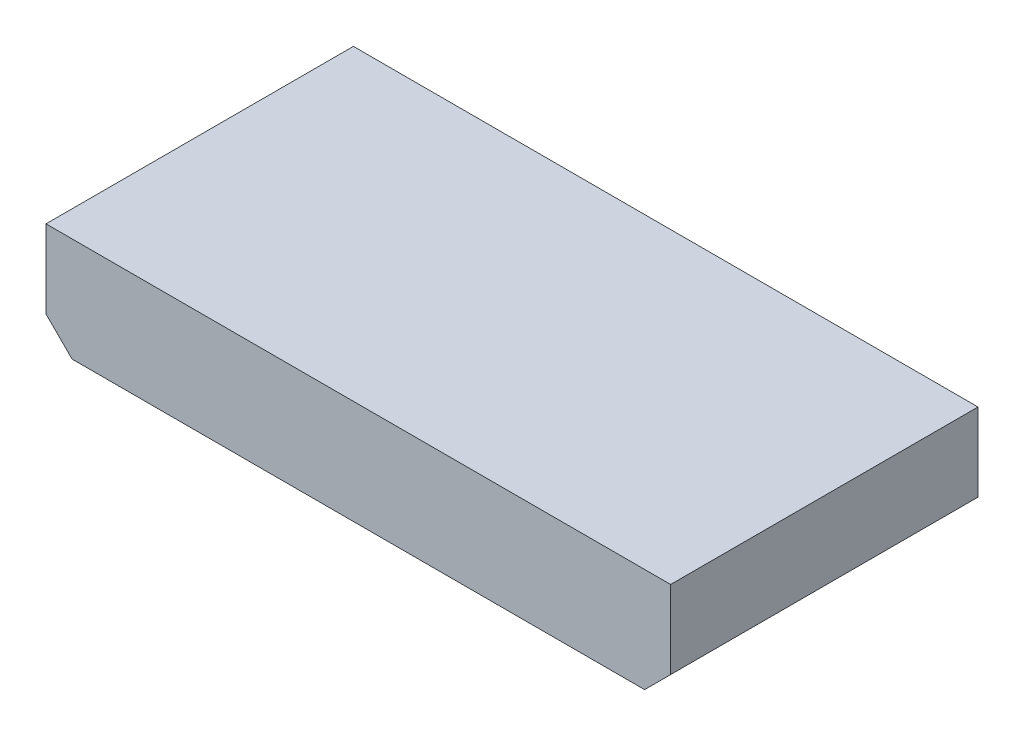
from build123d import *

# Parameters (mm, degrees)
COMPONENT_OUTLINE_DEPTH = 15
SKETCH2_R               = 0.25
EXTRUDE_1_DEPTH         = 2
SKETCH3_R               = 0.25
EXTRUDE_2_DEPTH         = 2
SKETCH4_R               = 0.25
EXTRUDE_3_DEPTH         = 2
SKETCH5_R               = 0.25
EXTRUDE_4_DEPTH         = 2
SKETCH6_R               = 0.25
EXTRUDE_5_DEPTH         = 2
SKETCH7_R               = 0.25
EXTRUDE_6_DEPTH         = 2
SKETCH8_R               = 0.25
EXTRUDE_7_DEPTH         = 2
SKETCH9_R               = 0.25
EXTRUDE_8_DEPTH         = 2
SKETCH10_R              = 0.25
EXTRUDE_9_DEPTH         = 2


with BuildPart() as part:
    # Sketch1 → Component_Outline (new body)
    with BuildSketch(Plane.XY):
        Polygon((-5.08, 2.54), (-5.08, -1.27), (-3.81, -2.54), (24.13, -2.54), (25.4, -1.27), (25.4, 2.54), align=None)
    extrude(amount=COMPONENT_OUTLINE_DEPTH)


with BuildPart() as body_2:
    # Sketch2 → Extrude 1 (new body)
    with BuildSketch(Plane.XY):
        Circle(SKETCH2_R)
    extrude(amount=-EXTRUDE_1_DEPTH)


with BuildPart() as body_3:
    # Sketch3 → Extrude 2 (new body)
    with BuildSketch(Plane.XY):
        with Locations((2.54, 0)):
            Circle(SKETCH3_R)
    extrude(amount=-EXTRUDE_2_DEPTH)


with BuildPart() as body_4:
    # Sketch4 → Extrude 3 (new body)
    with BuildSketch(Plane.XY):
        with Locations((5.08, 0)):
            Circle(SKETCH4_R)
    extrude(amount=-EXTRUDE_3_DEPTH)


with BuildPart() as body_5:
    # Sketch5 → Extrude 4 (new body)
    with BuildSketch(Plane.XY):
        with Locations((7.62, 0)):
            Circle(SKETCH5_R)
    extrude(amount=-EXTRUDE_4_DEPTH)


with BuildPart() as body_6:
    # Sketch6 → Extrude 5 (new body)
    with BuildSketch(Plane.XY):
        with Locations((10.16, 0)):
            Circle(SKETCH6_R)
    extrude(amount=-EXTRUDE_5_DEPTH)


with BuildPart() as body_7:
    # Sketch7 → Extrude 6 (new body)
    with BuildSketch(Plane.XY):
        with Locations((12.7, 0)):
            Circle(SKETCH7_R)
    extrude(amount=-EXTRUDE_6_DEPTH)


with BuildPart() as body_8:
    # Sketch8 → Extrude 7 (new body)
    with BuildSketch(Plane.XY):
        with Locations((15.24, 0)):
            Circle(SKETCH8_R)
    extrude(amount=-EXTRUDE_7_DEPTH)


with BuildPart() as body_9:
    # Sketch9 → Extrude 8 (new body)
    with BuildSketch(Plane.XY):
        with Locations((17.78, 0)):
            Circle(SKETCH9_R)
    extrude(amount=-EXTRUDE_8_DEPTH)


with BuildPart() as body_10:
    # Sketch10 → Extrude 9 (new body)
    with BuildSketch(Plane.XY):
        with Locations((20.32, 0)):
            Circle(SKETCH10_R)
    extrude(amount=-EXTRUDE_9_DEPTH)


solid = Compound([part.part, body_2.part, body_3.part, body_4.part, body_5.part, body_6.part, body_7.part, body_8.part, body_9.part, body_10.part])
